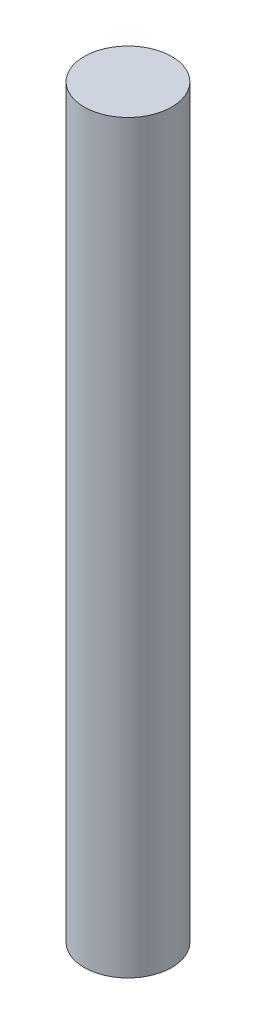
from build123d import *

# Parameters (mm, degrees)
SKETCH1_R           = 5.875
BOSS_EXTRUDE2_DEPTH = 20
SKETCH2_R           = 5.875
BOSS_EXTRUDE3_DEPTH = 80


with BuildPart() as part:
    # Sketch1 → Boss-Extrude2 (new body)
    with BuildSketch(Plane(origin=(0, 0, 0), x_dir=(1, 0, 0), z_dir=(0, 1, 0))):
        Circle(SKETCH1_R)
        with BuildLine():
            Line((-1.5, 2.111421322), (1.5, 2.111421322))
            ThreePointArc((1.5, 2.111421322), (0, -2.59), (-1.5, 2.111421322))
        make_face(mode=Mode.SUBTRACT)
    extrude(amount=BOSS_EXTRUDE2_DEPTH)

    # Sketch2 → Boss-Extrude3 (add)
    with BuildSketch(Plane(origin=(0, 20, 0), x_dir=(1, 0, 0), z_dir=(0, 1, 0))):
        Circle(SKETCH2_R)
    extrude(amount=BOSS_EXTRUDE3_DEPTH)


solid = part.part
